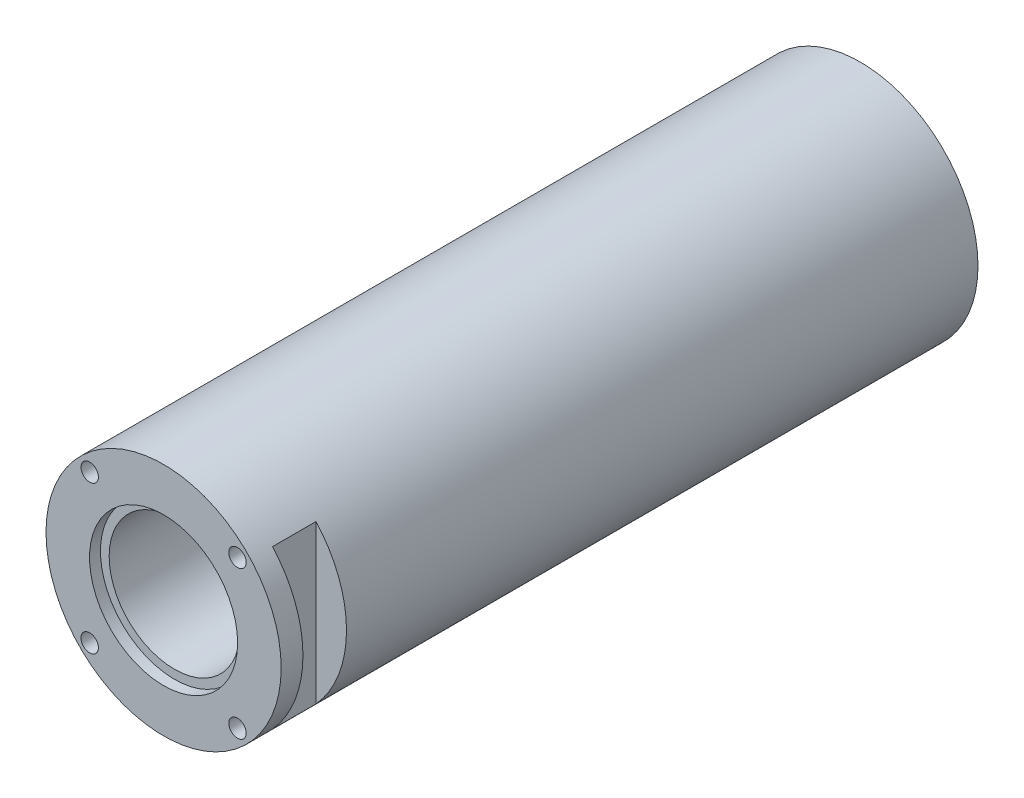
from build123d import *

# Parameters (mm, degrees)
ESQUISSE1_R           = 27
ESQUISSE1_R_2         = 15
EXTRUSION1_DEPTH      = 160
ESQUISSE2_R           = 2
EXTRUSION2_DEPTH      = 15
ESQUISSE3_R           = 2
EXTRUSION3_DEPTH      = 15
ESQUISSE4_R           = 17
ESQUISSE4_R_2         = 15
EXTRUSION4_DEPTH      = 2.5
ESQUISSE5_R           = 17
ESQUISSE5_R_2         = 15
EXTRUSION5_DEPTH      = 2.5
ESQUISSE6_W           = 120
ESQUISSE6_H           = 6
EXTRUSION6_DEPTH      = 28
EXTRUSION6_DEPTH_BACK = 28
ESQUISSE7_W           = 7
ESQUISSE7_H           = 10
EXTRUSION7_DEPTH      = 28
EXTRUSION7_DEPTH_BACK = 28


with BuildPart() as part:
    # Esquisse1 → Extrusion1 (new body)
    with BuildSketch(Plane.XY):
        Circle(ESQUISSE1_R)
        Circle(ESQUISSE1_R_2, mode=Mode.SUBTRACT)
    extrude(amount=EXTRUSION1_DEPTH)

    # Esquisse2 → Extrusion2 (cut)
    with BuildSketch(Plane.XY.offset(160)):
        with Locations((16.970013406, 16.971095673)):
            Circle(ESQUISSE2_R)
        with Locations((16.970013406, -16.970029824)):
            Circle(ESQUISSE2_R)
        with Locations((-16.971112091, -16.970029824)):
            Circle(ESQUISSE2_R)
        with Locations((-16.971112091, 16.971095673)):
            Circle(ESQUISSE2_R)
    extrude(amount=-EXTRUSION2_DEPTH, mode=Mode.SUBTRACT)

    # Esquisse3 → Extrusion3 (cut)
    with BuildSketch(Plane(origin=(0, 0, 0), x_dir=(-1, 0, 0), z_dir=(0, 0, -1))):
        with Locations((16.970013406, 16.971095673)):
            Circle(ESQUISSE3_R)
        with Locations((-16.971112091, 16.971095673)):
            Circle(ESQUISSE3_R)
        with Locations((-16.971112091, -16.970029824)):
            Circle(ESQUISSE3_R)
        with Locations((16.970013406, -16.970029824)):
            Circle(ESQUISSE3_R)
    extrude(amount=-EXTRUSION3_DEPTH, mode=Mode.SUBTRACT)

    # Esquisse4 → Extrusion4 (cut)
    with BuildSketch(Plane.XY.offset(160)):
        Circle(ESQUISSE4_R)
        Circle(ESQUISSE4_R_2, mode=Mode.SUBTRACT)
    extrude(amount=-EXTRUSION4_DEPTH, mode=Mode.SUBTRACT)

    # Esquisse5 → Extrusion5 (cut)
    with BuildSketch(Plane(origin=(0, 0, 0), x_dir=(-1, 0, 0), z_dir=(0, 0, -1))):
        Circle(ESQUISSE5_R)
        Circle(ESQUISSE5_R_2, mode=Mode.SUBTRACT)
    extrude(amount=-EXTRUSION5_DEPTH, mode=Mode.SUBTRACT)

    # Esquisse6 → Extrusion6 (cut, two sides)
    with BuildSketch(Plane(origin=(0, 0, 0), x_dir=(0, 0, -1), z_dir=(1, 0, 0))) as extrusion6_sk:
        with Locations((-80, -24)):
            Rectangle(ESQUISSE6_W, ESQUISSE6_H)
    extrude(amount=EXTRUSION6_DEPTH, mode=Mode.SUBTRACT)
    extrude(extrusion6_sk.sketch, amount=-EXTRUSION6_DEPTH_BACK, mode=Mode.SUBTRACT)

    # Esquisse7 → Extrusion7 (cut, two sides)
    with BuildSketch(Plane(origin=(0, 0, 0), x_dir=(1, 0, 0), z_dir=(0, 1, 0))) as extrusion7_sk:
        with Locations((23.5, -150)):
            Rectangle(ESQUISSE7_W, ESQUISSE7_H)
        with Locations((-23.5, -150)):
            Rectangle(ESQUISSE7_W, ESQUISSE7_H)
    extrude(amount=EXTRUSION7_DEPTH, mode=Mode.SUBTRACT)
    extrude(extrusion7_sk.sketch, amount=-EXTRUSION7_DEPTH_BACK, mode=Mode.SUBTRACT)


solid = part.part
